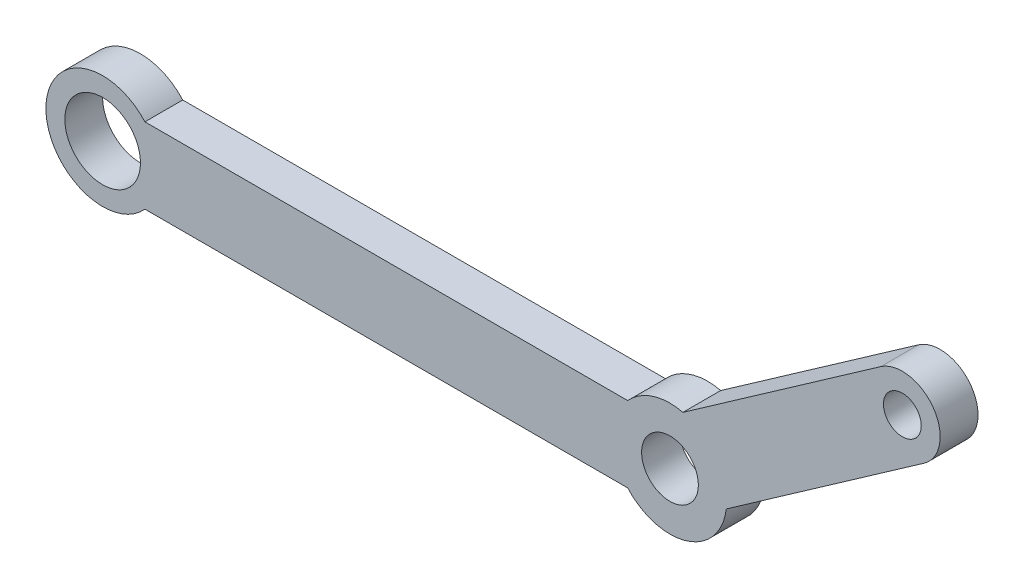
from build123d import *

# Parameters (mm, degrees)
EXTRUDE_1_DEPTH     = 2
SKETCH_2_R          = 2
SKETCH_2_R_2        = 1.5
SKETCH_2_R_3        = 1
CUT_EXTRUDE_1_DEPTH = 2


with BuildPart() as part:
    # 草图1 → 凸台-拉伸1 (new body)
    with BuildSketch(Plane.XY):
        with BuildLine():
            Line((41.140127792, 10.241950634), (30.684526782, 2.920859991))
            ThreePointArc((30.684526782, 2.920859991), (29.097882601, 2.861150852), (27.763932023, 2))
            Line((27.763932023, 2), (2.236067977, 2))
            ThreePointArc((2.236067977, 2), (-3, 0), (2.236067977, -2))
            Line((2.236067977, -2), (27.763932023, -2))
            ThreePointArc((27.763932023, -2), (30.902117399, -2.861150852), (32.978832528, -0.355748187))
            Line((32.978832528, -0.355748187), (43.434433537, 6.965342457))
            ThreePointArc((43.434433537, 6.965342457), (43.925584753, 9.750799418), (41.140127792, 10.241950634))
        make_face()
    extrude(amount=EXTRUDE_1_DEPTH)

    # 草图2 → 切除-拉伸1 (cut)
    with BuildSketch(Plane.XY.offset(2)):
        Circle(SKETCH_2_R)
        with Locations((30, 0)):
            Circle(SKETCH_2_R_2)
        with Locations((42.287280664, 8.603646545)):
            Circle(SKETCH_2_R_3)
    extrude(amount=-CUT_EXTRUDE_1_DEPTH, mode=Mode.SUBTRACT)


solid = part.part
